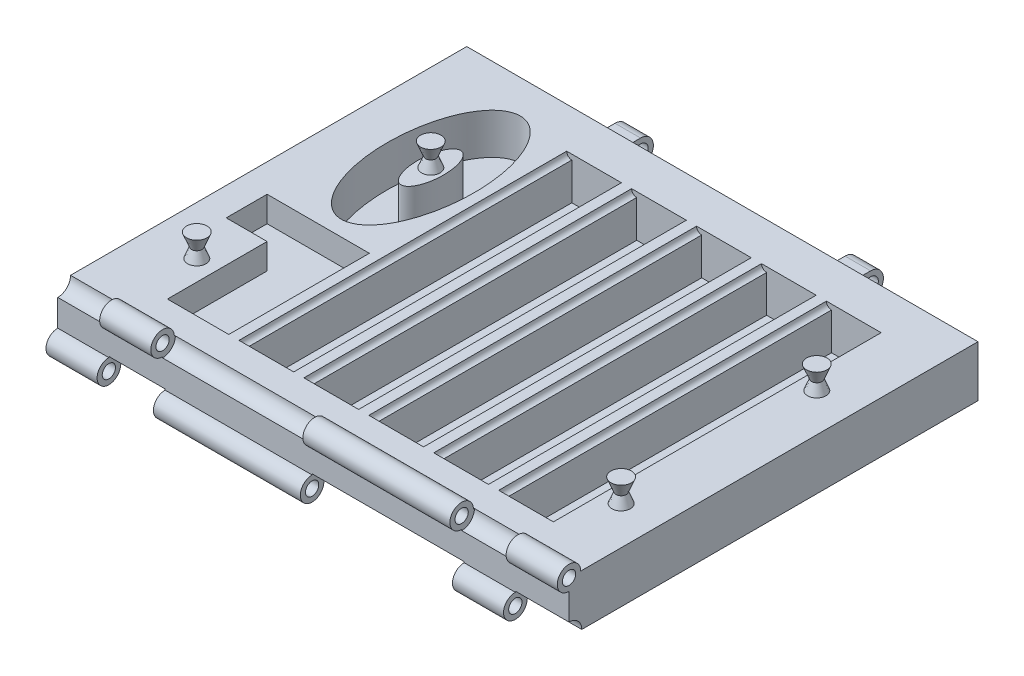
from build123d import *

# Parameters (mm, degrees)
SKETCH1_W            = 254
SKETCH1_H            = 203.2
BOSS_EXTRUDE2_DEPTH  = 25.4
SKETCH2_W            = 24.638
SKETCH2_H            = 162.814
CUT_EXTRUDE1_DEPTH   = 20.955
SKETCH3_R            = 2.54
CUT_EXTRUDE2_DEPTH   = 162.814
SKETCH4_R            = 6.35
CUT_EXTRUDE3_DEPTH   = 330.708
SKETCH5_R            = 5.842
SKETCH5_R_2          = 3.302
BOSS_EXTRUDE3_DEPTH  = 25.4
SKETCH7_R            = 5.842
SKETCH7_R_2          = 3.302
BOSS_EXTRUDE4_DEPTH  = 25.4
SKETCH9_R            = 5.842
SKETCH9_R_2          = 3.302
BOSS_EXTRUDE5_DEPTH  = 73.025
SKETCH11_R           = 6.35
CUT_EXTRUDE4_DEPTH   = 271.907
SKETCH12_R           = 5.842
SKETCH12_R_2         = 3.302
BOSS_EXTRUDE6_DEPTH  = 25.4
SKETCH14_R           = 5.842
SKETCH14_R_2         = 3.302
BOSS_EXTRUDE7_DEPTH  = 73.025
SKETCH17_R           = 5.842
SKETCH17_R_2         = 3.302
BOSS_EXTRUDE8_DEPTH  = 25.4
CUT_EXTRUDE5_DEPTH   = 12.7
SKETCH20_RX          = 44.45
SKETCH20_RY          = 21.59
SKETCH20_RX_2        = 14.8082
SKETCH20_RY_2        = 6.35
CUT_EXTRUDE6_DEPTH   = 20.32
SKETCH24_R           = 2.54
BOSS_EXTRUDE9_DEPTH  = 5.08
SKETCH25_R           = 2.54
BOSS_EXTRUDE10_DEPTH = 5.08
SKETCH28_R           = 6.35
BOSS_EXTRUDE11_DEPTH = 12.7
SKETCH30_R           = 6.35
BOSS_EXTRUDE12_DEPTH = 12.7
SKETCH31_R           = 3.81
CUT_EXTRUDE7_DEPTH   = 150.114
FILLET1_R            = 5.08


with BuildPart() as part:
    # Sketch1 → Boss-Extrude2 (new body)
    with BuildSketch(Plane(origin=(0, 0, 0), x_dir=(1, 0, 0), z_dir=(0, 1, 0))):
        with Locations((127, 101.6)):
            Rectangle(SKETCH1_W, SKETCH1_H)
    extrude(amount=BOSS_EXTRUDE2_DEPTH)

    # Sketch2 → Cut-Extrude1 (cut)
    with BuildSketch(Plane(origin=(0, 25.4, 0), x_dir=(1, 0, 0), z_dir=(0, 1, 0))):
        with Locations((84.709, 101.6)):
            Rectangle(SKETCH2_W, SKETCH2_H)
        with Locations((116.967, 101.6)):
            Rectangle(SKETCH2_W, SKETCH2_H)
        with Locations((149.225, 101.6)):
            Rectangle(SKETCH2_W, SKETCH2_H)
        with Locations((181.483, 101.6)):
            Rectangle(SKETCH2_W, SKETCH2_H)
        with Locations((213.741, 101.6)):
            Rectangle(SKETCH2_W, SKETCH2_H)
    extrude(amount=-CUT_EXTRUDE1_DEPTH, mode=Mode.SUBTRACT)

    # Sketch3 → Cut-Extrude2 (cut)
    with BuildSketch(Plane.XY.offset(-183.007)):
        with Locations((72.39, 25.4)):
            Circle(SKETCH3_R)
        with Locations((104.648, 25.4)):
            Circle(SKETCH3_R)
        with Locations((136.906, 25.4)):
            Circle(SKETCH3_R)
        with Locations((169.164, 25.4)):
            Circle(SKETCH3_R)
        with Locations((201.422, 25.4)):
            Circle(SKETCH3_R)
    extrude(amount=CUT_EXTRUDE2_DEPTH, mode=Mode.SUBTRACT)

    # Sketch4 → Cut-Extrude3 (cut)
    with BuildSketch(Plane(origin=(254, 0, 0), x_dir=(0, 0, -1), z_dir=(1, 0, 0))):
        with Locations((0, 25.4)):
            Circle(SKETCH4_R)
    extrude(amount=-CUT_EXTRUDE3_DEPTH, mode=Mode.SUBTRACT)

    # Sketch5 → Boss-Extrude3 (add)
    with BuildSketch(Plane(origin=(254, 0, 0), x_dir=(0, 0, -1), z_dir=(1, 0, 0))):
        with BuildLine():
            ThreePointArc((5.842, 25.4), (4.130917816, 21.269082184), (0, 19.558))
            Line((0, 19.558), (0, 19.05))
            ThreePointArc((0, 19.05), (4.490128061, 20.909871939), (6.35, 25.4))
            Line((6.35, 25.4), (5.842, 25.4))
        make_face()
        with Locations((0, 25.4)):
            Circle(SKETCH5_R)
        with Locations((0, 25.4)):
            Circle(SKETCH5_R_2, mode=Mode.SUBTRACT)
    extrude(amount=-BOSS_EXTRUDE3_DEPTH)

    # Sketch7 → Boss-Extrude4 (add)
    with BuildSketch(Plane.ZY.offset(-26.67)):
        with BuildLine():
            ThreePointArc((0, 19.558), (-4.130917816, 21.269082184), (-5.842, 25.4))
            Line((-5.842, 25.4), (-6.902928933, 25.4))
            Line((-6.902928933, 25.4), (-6.372464466, 22.098))
            Line((-6.372464466, 22.098), (-4.097007923, 19.395027099))
            Line((-4.097007923, 19.395027099), (0, 18.4548232))
            Line((0, 18.4548232), (0, 19.558))
        make_face()
        with Locations((0, 25.4)):
            Circle(SKETCH7_R)
        with Locations((0, 25.4)):
            Circle(SKETCH7_R_2, mode=Mode.SUBTRACT)
    extrude(amount=-BOSS_EXTRUDE4_DEPTH)

    # Sketch9 → Boss-Extrude5 (add)
    with BuildSketch(Plane(origin=(200.66, 0, 0), x_dir=(0, 0, -1), z_dir=(1, 0, 0))):
        with BuildLine():
            Line((7.296114835, 25.4), (5.842, 25.4))
            ThreePointArc((5.842, 25.4), (4.130917816, 21.269082184), (0, 19.558))
            Line((0, 19.558), (0, 18.462733019))
            Line((0, 18.462733019), (2.519044433, 18.922066711))
            Line((2.519044433, 18.922066711), (5.842, 20.162267681))
            Line((5.842, 20.162267681), (7.296114835, 25.4))
        make_face()
        with Locations((0, 25.4)):
            Circle(SKETCH9_R)
        with Locations((0, 25.4)):
            Circle(SKETCH9_R_2, mode=Mode.SUBTRACT)
    extrude(amount=-BOSS_EXTRUDE5_DEPTH)

    # Sketch11 → Cut-Extrude4 (cut)
    with BuildSketch(Plane(origin=(254, 0, 0), x_dir=(0, 0, -1), z_dir=(1, 0, 0))):
        Circle(SKETCH11_R)
    extrude(amount=-CUT_EXTRUDE4_DEPTH, mode=Mode.SUBTRACT)

    # Sketch12 → Boss-Extrude6 (add)
    with BuildSketch(Plane.ZY):
        with BuildLine():
            ThreePointArc((-5.842, 0), (-4.130917816, 4.130917816), (0, 5.842))
            Line((0, 5.842), (0, 6.35))
            ThreePointArc((0, 6.35), (-4.490128061, 4.490128061), (-6.35, 0))
            Line((-6.35, 0), (-5.842, 0))
        make_face()
        Circle(SKETCH12_R)
        Circle(SKETCH12_R_2, mode=Mode.SUBTRACT)
    extrude(amount=-BOSS_EXTRUDE6_DEPTH)

    # Sketch14 → Boss-Extrude7 (add)
    with BuildSketch(Plane.ZY.offset(-53.34)):
        with BuildLine():
            ThreePointArc((-5.842, 0), (-4.130917816, 4.130917816), (0, 5.842))
            Line((0, 5.842), (0, 7.34197102))
            Line((0, 7.34197102), (-6.416971857, 5.34789306))
            Line((-6.416971857, 5.34789306), (-7.97079884, 0))
            Line((-7.97079884, 0), (-5.842, 0))
        make_face()
        Circle(SKETCH14_R)
        Circle(SKETCH14_R_2, mode=Mode.SUBTRACT)
    extrude(amount=-BOSS_EXTRUDE7_DEPTH)

    # Sketch17 → Boss-Extrude8 (add)
    with BuildSketch(Plane(origin=(227.33, 0, 0), x_dir=(0, 0, -1), z_dir=(1, 0, 0))):
        with BuildLine():
            Line((0, 7.437449264), (0, 5.842))
            ThreePointArc((0, 5.842), (4.130917816, 4.130917816), (5.842, 0))
            Line((5.842, 0), (6.728774343, 0))
            Line((6.728774343, 0), (5.842, 4.854950807))
            Line((5.842, 4.854950807), (0, 7.437449264))
        make_face()
        Circle(SKETCH17_R)
        Circle(SKETCH17_R_2, mode=Mode.SUBTRACT)
    extrude(amount=-BOSS_EXTRUDE8_DEPTH)

    # Sketch19 → Cut-Extrude5 (cut)
    with BuildSketch(Plane(origin=(0, 25.4, 0), x_dir=(1, 0, 0), z_dir=(0, 1, 0))):
        Polygon((13.97, 90.043), (64.77, 90.043), (64.77, 20.193), (34.29, 20.193), (34.29, 69.723), (13.97, 69.723), align=None)
    extrude(amount=-CUT_EXTRUDE5_DEPTH, mode=Mode.SUBTRACT)

    # Sketch20 → Cut-Extrude6 (cut)
    with BuildSketch(Plane(origin=(0, 25.4, 0), x_dir=(1, 0, 0), z_dir=(0, 1, 0))):
        with Locations(Location((43.18, 142.163874998), (0, 0, -90))):
            Ellipse(SKETCH20_RX, SKETCH20_RY)
        with Locations(Location((43.18, 142.163874998), (0, 0, 90))):
            Ellipse(SKETCH20_RX_2, SKETCH20_RY_2, mode=Mode.SUBTRACT)
    extrude(amount=-CUT_EXTRUDE6_DEPTH, mode=Mode.SUBTRACT)

    # Sketch24 → Boss-Extrude9 (add)
    with BuildSketch(Plane(origin=(0, 25.4, 0), x_dir=(1, 0, 0), z_dir=(0, 1, 0))):
        with Locations((24.13, 44.958)):
            Circle(SKETCH24_R)
        with Locations((234.95, 44.958)):
            Circle(SKETCH24_R)
    extrude(amount=BOSS_EXTRUDE9_DEPTH)

    # Sketch25 → Boss-Extrude10 (add)
    with BuildSketch(Plane(origin=(0, 25.4, 0), x_dir=(1, 0, 0), z_dir=(0, 1, 0))):
        with Locations((43.18, 142.163874998)):
            Circle(SKETCH25_R)
        with Locations((234.95, 142.163874998)):
            Circle(SKETCH25_R)
    extrude(amount=BOSS_EXTRUDE10_DEPTH)

    # Sketch28 → Boss-Extrude11 (add)
    with BuildSketch(Plane(origin=(177.8, 0, 0), x_dir=(0, 0, -1), z_dir=(1, 0, 0))):
        with BuildLine():
            Line((203.2, 19.05), (203.2, 12.7))
            Line((203.2, 12.7), (203.2, 6.35))
            Line((203.2, 6.35), (213.36, 6.35))
            ThreePointArc((213.36, 6.35), (207.01, 12.7), (213.36, 19.05))
            Line((213.36, 19.05), (203.2, 19.05))
        make_face()
        with Locations((213.36, 12.7)):
            Circle(SKETCH28_R)
    extrude(amount=BOSS_EXTRUDE11_DEPTH)

    # Sketch30 → Boss-Extrude12 (add)
    with BuildSketch(Plane(origin=(76.2, 0, 0), x_dir=(0, 0, -1), z_dir=(1, 0, 0))):
        with BuildLine():
            Line((213.36, 19.05), (203.2, 19.05))
            Line((203.2, 19.05), (203.2, 6.35))
            Line((203.2, 6.35), (213.36, 6.35))
            ThreePointArc((213.36, 6.35), (207.01, 12.7), (213.36, 19.05))
        make_face()
        with Locations((213.36, 12.7)):
            Circle(SKETCH30_R)
    extrude(amount=-BOSS_EXTRUDE12_DEPTH)

    # Sketch31 → Cut-Extrude7 (cut)
    with BuildSketch(Plane(origin=(190.5, 0, 0), x_dir=(0, 0, -1), z_dir=(1, 0, 0))):
        with Locations((213.36, 12.7)):
            Circle(SKETCH31_R)
    extrude(amount=-CUT_EXTRUDE7_DEPTH, mode=Mode.SUBTRACT)

    # Fillet1
    fillet1_edges = [part.edges().sort_by_distance(p)[0] for p in [
        (184.15, 6.35, -203.2),
        (184.15, 19.05, -203.2),
        (69.85, 6.35, -203.2),
        (69.85, 19.05, -203.2),
    ]]
    fillet(fillet1_edges, radius=FILLET1_R)

    # Sketch34 → Revolve1 (revolve)
    with BuildSketch(Plane(origin=(0, 0, -142.163874998), x_dir=(-1, 0, 0), z_dir=(0, 0, -1))):
        Polygon((-234.95, 24.13), (-234.95, 36.83), (-240.03, 36.83), (-237.49, 30.48), (-240.03, 24.13), align=None)
    revolve(axis=Axis((234.95, 24.13, -142.163874998), (0, 1, 0)))

    # Sketch35 → Revolve2 (revolve)
    with BuildSketch(Plane(origin=(0, 0, -142.163874998), x_dir=(-1, 0, 0), z_dir=(0, 0, -1))):
        Polygon((-43.18, 24.13), (-43.18, 36.83), (-38.1, 36.83), (-40.64, 30.48), (-38.1, 24.13), align=None)
    revolve(axis=Axis((43.18, 24.13, -142.163874998), (0, 1, 0)))

    # Sketch38 → Revolve3 (revolve)
    with BuildSketch(Plane(origin=(0, 0, -44.958), x_dir=(-1, 0, 0), z_dir=(0, 0, -1))):
        Polygon((-232.41, 30.48), (-229.87, 36.83), (-234.95, 36.83), (-234.95, 24.13), (-229.87, 24.13), align=None)
    revolve(axis=Axis((234.95, 36.83, -44.958), (0, -1, 0)))

    # Sketch39 → Revolve7 (revolve)
    with BuildSketch(Plane(origin=(0, 0, -44.958), x_dir=(-1, 0, 0), z_dir=(0, 0, -1))):
        Polygon((-24.13, 24.13), (-24.13, 36.83), (-19.05, 36.83), (-21.59, 30.48), (-19.05, 24.13), align=None)
    revolve(axis=Axis((24.13, 24.13, -44.958), (0, 1, 0)))


solid = part.part
